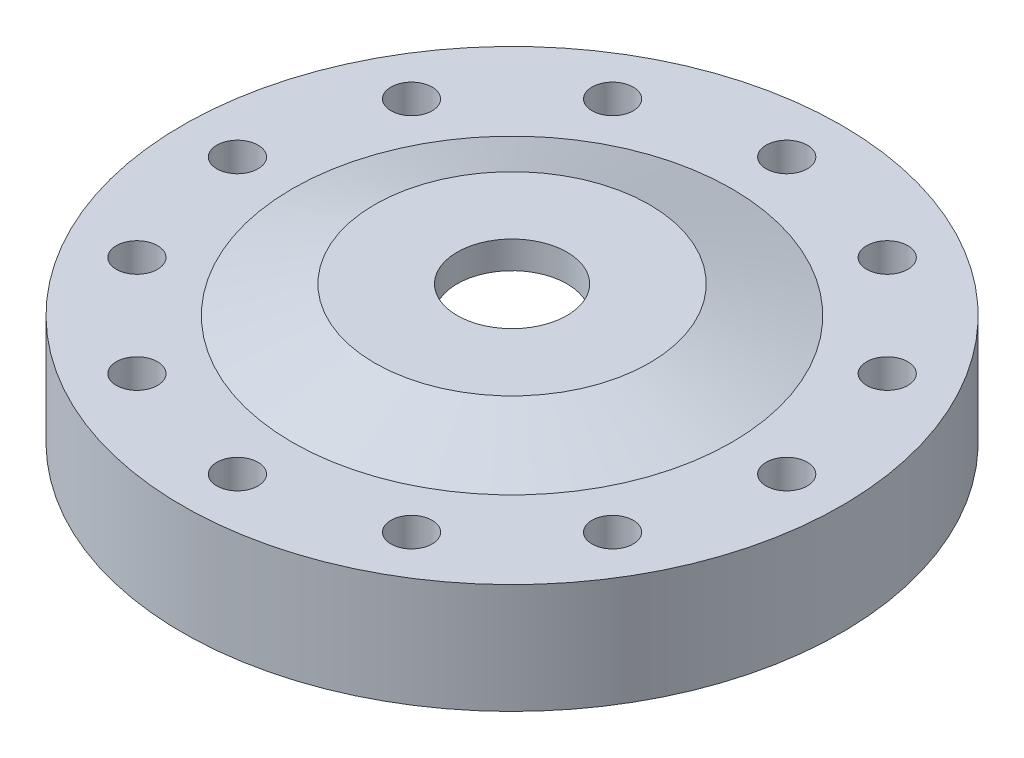
from build123d import *

# Parameters (mm, degrees)
CIRPATTERN1_COUNT = 12


with BuildPart() as part:
    # Sketch1 → Revolve1 (revolve)
    with BuildSketch(Plane.XY):
        Polygon((-76.2, 0), (-76.2, 25.4), (-50.8, 25.4), (-31.75, 31.75), (-12.7, 31.75), (-12.7, 25.4), (-31.75, 15.875), (-31.75, 12.7), (-33.3375, 12.7), (-33.3375, 14.732), (-36.0807, 14.732), (-36.0807, 12.7), (-50.8, 12.7), (-50.8, 0), (-52.3875, 0), (-52.3875, 2.032), (-55.1307, 2.032), (-55.1307, 0), align=None)
    revolve(axis=Axis((0, -1.5875, 0), (0, 1, 0)))

    # Sketch3 → 3/8 (0.375) Diameter Hole1 (revolve, cut)
    with BuildSketch(Plane(origin=(-63.5, 25.4, 0), x_dir=(0, 0, 1), z_dir=(1, 0, 0))):
        Polygon((0, 0), (0, 53.661598698), (4.7625, 50.8), (4.7625, 0), align=None)
    f_3_8_0_375_diameter_hole1 = revolve(axis=Axis((-63.5, 31.75, 0), (0, -1, 0)), mode=Mode.SUBTRACT)

    # CirPattern1: 3/8 (0.375) Diameter Hole1 ×12 about axis
    cirpattern1_axis = Axis((0, 0, 0), (0, 1, 0))
    for i in range(1, CIRPATTERN1_COUNT):
        add(f_3_8_0_375_diameter_hole1.rotate(cirpattern1_axis, i * 360 / CIRPATTERN1_COUNT), mode=Mode.SUBTRACT)


solid = part.part
